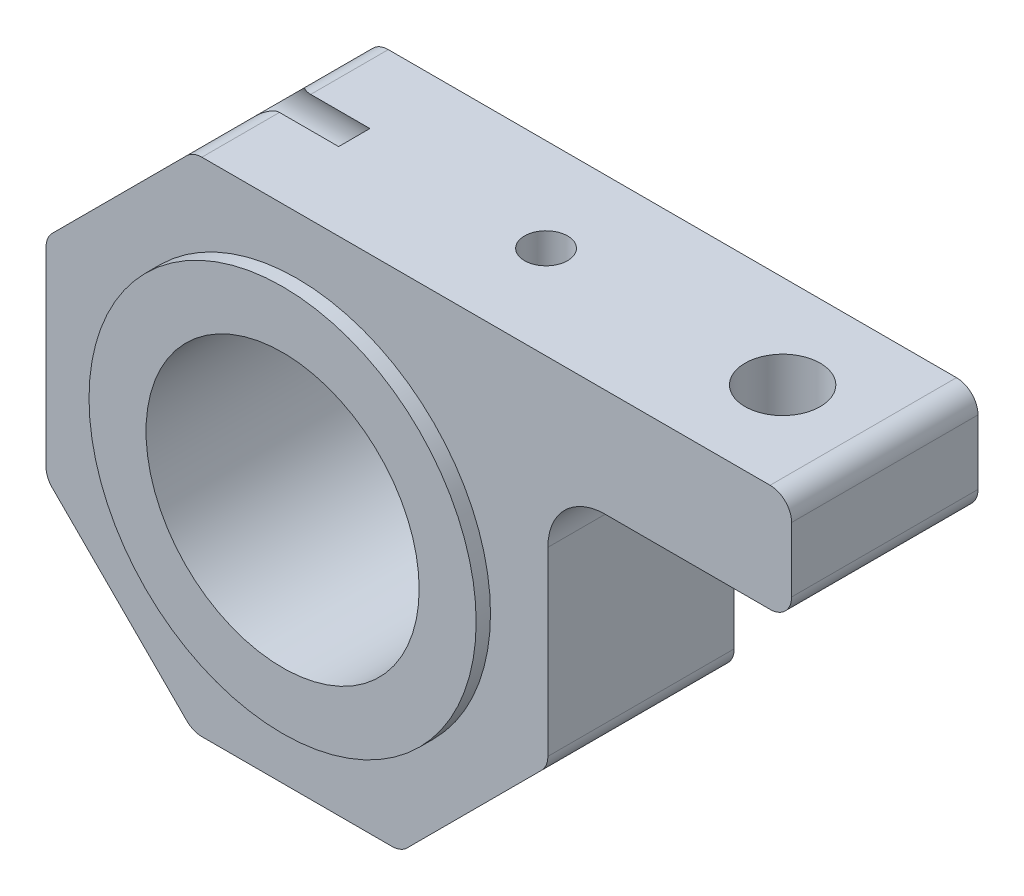
from build123d import *

# Parameters (mm, degrees)
SKETCH1_R           = 19.05
BOSS_EXTRUDE1_DEPTH = 13
FILLET1_R           = 8
FILLET2_R           = 3
SKETCH2_R           = 27
SKETCH2_R_2         = 19.05
BOSS_EXTRUDE2_DEPTH = 15
SKETCH3_R           = 5
CUT_EXTRUDE1_DEPTH  = 30
SKETCH4_R           = 5.25
SKETCH4_R_2         = 3
CUT_EXTRUDE2_DEPTH  = 15


with BuildPart() as part:
    # Sketch1 → Boss-Extrude1 (new body, symmetric)
    with BuildSketch(Plane.XY):
        Polygon((14.497474683, 35), (0, 35), (-14.497474683, 35), (-35, 14.497474683), (-35, -14.497474683), (-14.497474683, -35), (14.497474683, -35), (35, -14.497474683), (35, 20), (69, 20), (69, 35), align=None)
        Circle(SKETCH1_R, mode=Mode.SUBTRACT)
    extrude(amount=BOSS_EXTRUDE1_DEPTH, both=True)

    # Fillet1
    fillet1_edges = [part.edges().sort_by_distance(p)[0] for p in [
        (35, 20, 0),
    ]]
    fillet(fillet1_edges, radius=FILLET1_R)

    # Fillet2
    fillet2_edges = [part.edges().sort_by_distance(p)[0] for p in [
        (69, 35, 0),
        (69, 20, 0),
        (35, -14.497474683, 0),
        (14.497474683, -35, 0),
        (-14.497474683, -35, 0),
        (-35, -14.497474683, 0),
        (-35, 14.497474683, 0),
        (-14.497474683, 35, 0),
    ]]
    fillet(fillet2_edges, radius=FILLET2_R)

    # Sketch2 → Boss-Extrude2 (add, symmetric)
    with BuildSketch(Plane.XY):
        Circle(SKETCH2_R)
        Circle(SKETCH2_R_2, mode=Mode.SUBTRACT)
    extrude(amount=BOSS_EXTRUDE2_DEPTH, both=True)

    # Sketch3 → Cut-Extrude1 (cut)
    with BuildSketch(Plane.ZY.offset(35)):
        with Locations((0, -30.5)):
            Circle(SKETCH3_R)
        with Locations((0, 30.5)):
            Circle(SKETCH3_R)
    extrude(amount=-CUT_EXTRUDE1_DEPTH, mode=Mode.SUBTRACT)

    # Sketch4 → Cut-Extrude2 (cut)
    with BuildSketch(Plane(origin=(0, 35, 0), x_dir=(1, 0, 0), z_dir=(0, 1, 0))):
        with Locations((54.75, 0)):
            Circle(SKETCH4_R)
        with Locations((21.75, 0)):
            Circle(SKETCH4_R_2)
    extrude(amount=-CUT_EXTRUDE2_DEPTH, mode=Mode.SUBTRACT)


solid = part.part
